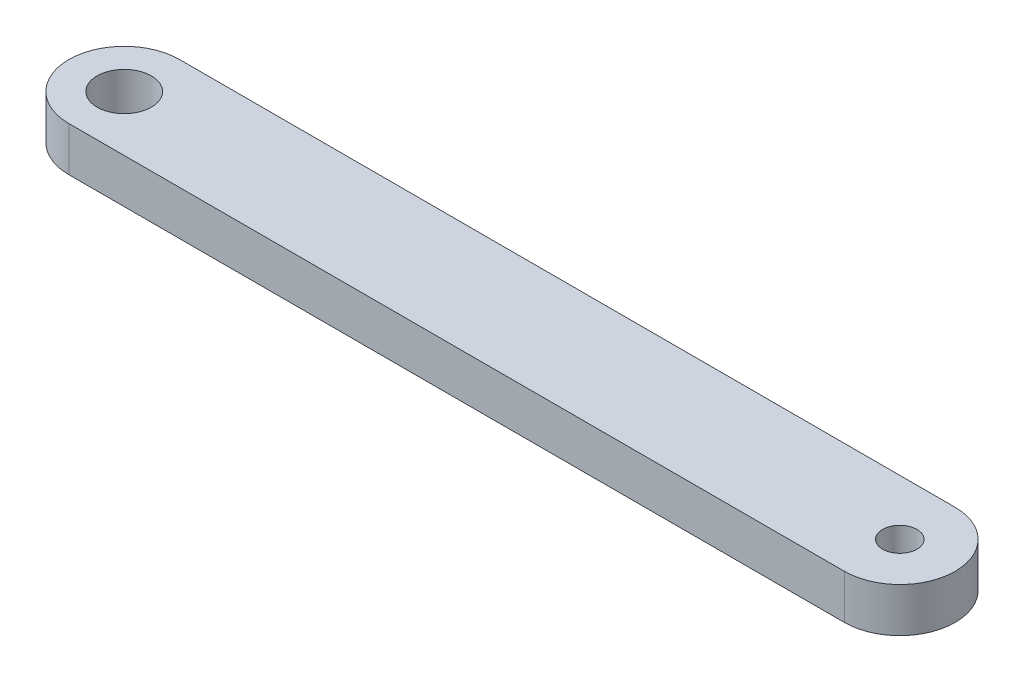
from build123d import *

# Parameters (mm, degrees)
SKETCH1_R           = 2.45
SKETCH1_R_2         = 1.55
BOSS_EXTRUDE1_DEPTH = 4


with BuildPart() as part:
    # Sketch1 → Boss-Extrude1 (new body)
    with BuildSketch(Plane(origin=(0, 0, 0), x_dir=(1, 0, 0), z_dir=(0, 1, 0))):
        with BuildLine():
            Line((0, -5), (-70, -5))
            ThreePointArc((-70, -5), (-75, 0), (-70, 5))
            Line((-70, 5), (0, 5))
            ThreePointArc((0, 5), (5, 0), (0, -5))
        make_face()
        with Locations((-70, 0)):
            Circle(SKETCH1_R, mode=Mode.SUBTRACT)
        Circle(SKETCH1_R_2, mode=Mode.SUBTRACT)
    extrude(amount=BOSS_EXTRUDE1_DEPTH)


solid = part.part
